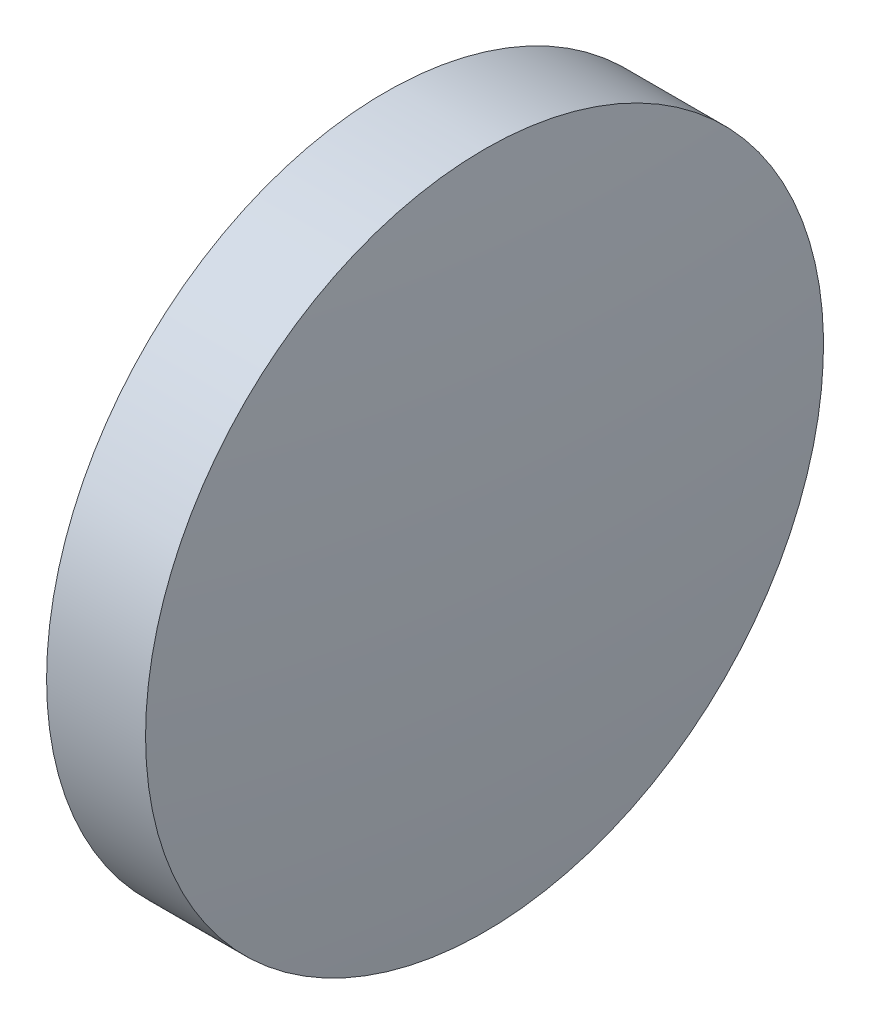
from build123d import *


with BuildPart() as part:
    # 草图1 → 旋转1 (revolve)
    with BuildSketch(Plane.XY):
        with BuildLine():
            Line((862.246324151, 272.066761118), (862.246324151, 277.066761118))
            Line((862.246324151, 277.066761118), (863.706324151, 277.066761118))
            ThreePointArc((863.706324151, 277.066761118), (863.886289631, 274.569639461), (863.946324151, 272.066761118))
            Line((863.946324151, 272.066761118), (862.246324151, 272.066761118))
        make_face()
    revolve(axis=Axis((861.014803577, 272.066761118, 0), (1, 0, 0)))


solid = part.part
